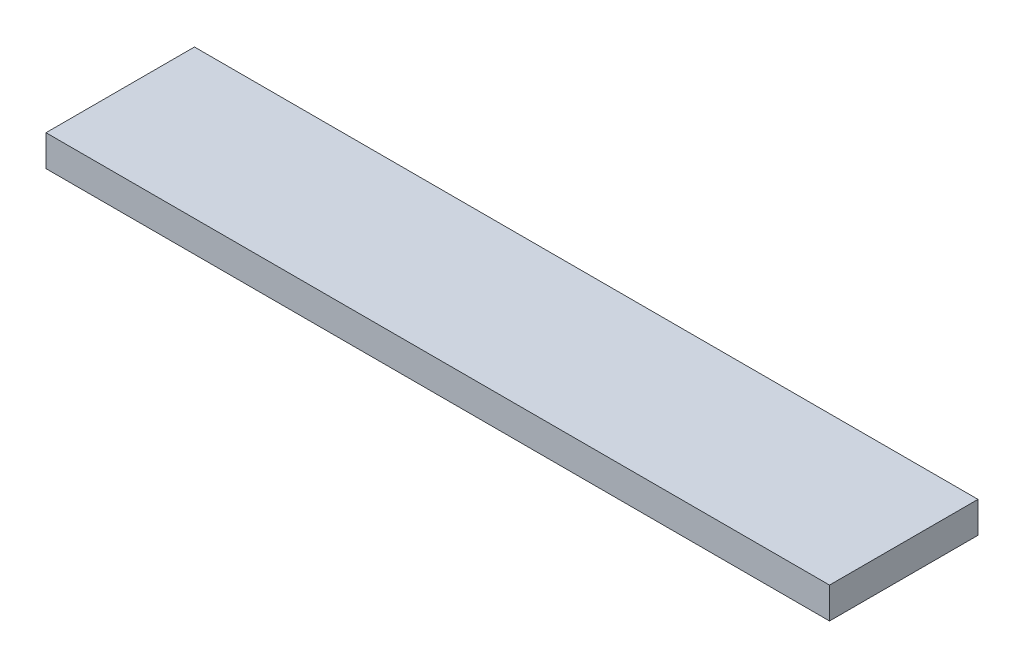
from build123d import *

# Parameters (mm, degrees)
SKETCH1_W           = 479.3488
SKETCH1_H           = 90.8304
BOSS_EXTRUDE1_DEPTH = 19.05


with BuildPart() as part:
    # Sketch1 → Boss-Extrude1 (new body)
    with BuildSketch(Plane(origin=(0, 0, 0), x_dir=(1, 0, 0), z_dir=(0, 1, 0))):
        with Locations((239.6744, 45.4152)):
            Rectangle(SKETCH1_W, SKETCH1_H)
    extrude(amount=BOSS_EXTRUDE1_DEPTH)


solid = part.part
